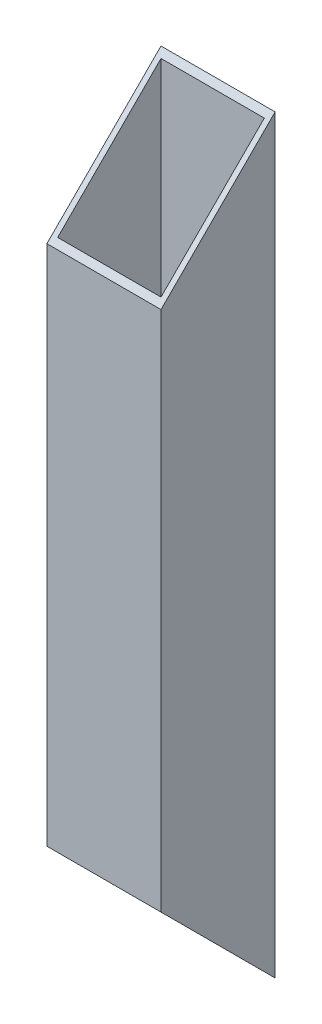
from build123d import *

# Parameters (mm, degrees)
SKETCH1_W           = 25.4
SKETCH1_H           = 25.4
SKETCH1_W_2         = 23
SKETCH1_H_2         = 23
BOSS_EXTRUDE1_DEPTH = 166.94
CUT_EXTRUDE1_DEPTH  = 26.4


with BuildPart() as part:
    # Sketch1 → Boss-Extrude1 (new body)
    with BuildSketch(Plane(origin=(0, 0, 0), x_dir=(1, 0, 0), z_dir=(0, 1, 0))):
        with Locations((12.7, 12.7)):
            Rectangle(SKETCH1_W, SKETCH1_H)
        with Locations((12.7, 12.7)):
            Rectangle(SKETCH1_W_2, SKETCH1_H_2, mode=Mode.SUBTRACT)
    extrude(amount=BOSS_EXTRUDE1_DEPTH)

    # Sketch2 → Cut-Extrude1 (cut, through all)
    with BuildSketch(Plane(origin=(25.4, 0, 0), x_dir=(0, 0, -1), z_dir=(1, 0, 0))):
        Polygon((25.4, 166.94), (0, 166.94), (0, 141.54), align=None)
        Polygon((0, 0), (0, 25.4), (25.4, 0), align=None)
    extrude(amount=-CUT_EXTRUDE1_DEPTH, mode=Mode.SUBTRACT)


solid = part.part
